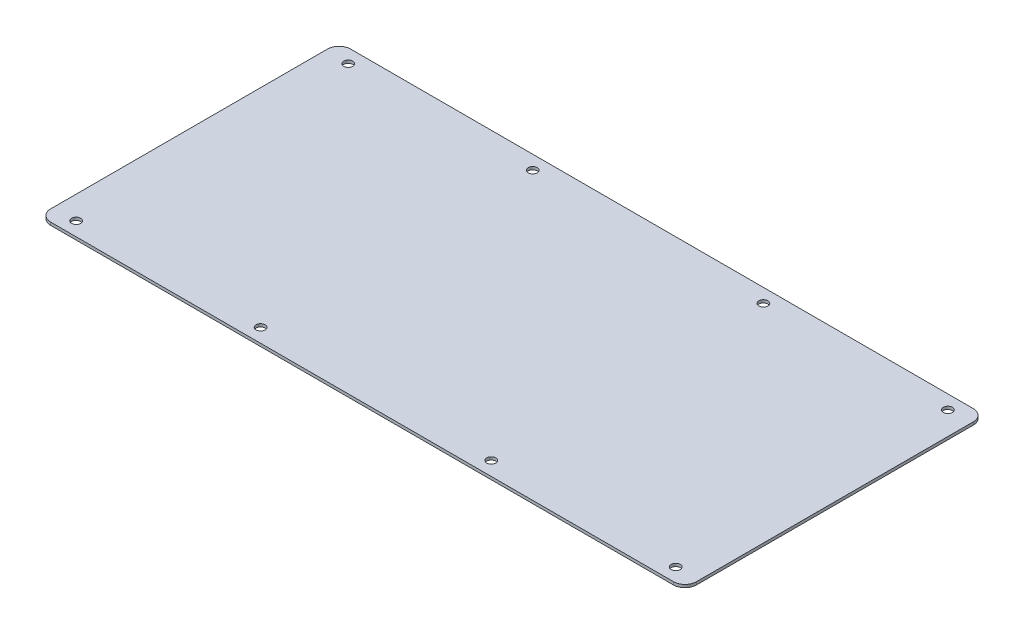
from build123d import *

# Parameters (mm, degrees)
SKETCH1_W           = 355.6
SKETCH1_H           = 165.1
BOSS_EXTRUDE1_DEPTH = 1.5875
FILLET1_R           = 6.35
SKETCH2_R           = 2.4892
CUT_EXTRUDE1_DEPTH  = 2.5875


with BuildPart() as part:
    # Sketch1 → Boss-Extrude1 (new body)
    with BuildSketch(Plane(origin=(0, 0, 0), x_dir=(1, 0, 0), z_dir=(0, 1, 0))):
        with Locations((177.8, 82.55)):
            Rectangle(SKETCH1_W, SKETCH1_H)
    extrude(amount=BOSS_EXTRUDE1_DEPTH)

    # Fillet1
    fillet1_edges = [part.edges().sort_by_distance(p)[0] for p in [
        (0, 0.79375, -165.1),
        (355.6, 0.79375, -165.1),
        (355.6, 0.79375, 0),
        (0, 0.79375, 0),
    ]]
    fillet(fillet1_edges, radius=FILLET1_R)

    # Sketch2 → Cut-Extrude1 (cut, through all)
    with BuildSketch(Plane(origin=(0, 1.5875, 0), x_dir=(1, 0, 0), z_dir=(0, 1, 0))):
        with Locations((12.7, 7.62)):
            Circle(SKETCH2_R)
        with Locations((342.9, 7.62)):
            Circle(SKETCH2_R)
        with Locations((241.3, 7.62)):
            Circle(SKETCH2_R)
        with Locations((114.3, 7.62)):
            Circle(SKETCH2_R)
        with Locations((114.3, 157.48)):
            Circle(SKETCH2_R)
        with Locations((342.9, 157.48)):
            Circle(SKETCH2_R)
        with Locations((12.7, 157.48)):
            Circle(SKETCH2_R)
        with Locations((241.3, 157.48)):
            Circle(SKETCH2_R)
    extrude(amount=-CUT_EXTRUDE1_DEPTH, mode=Mode.SUBTRACT)


solid = part.part
